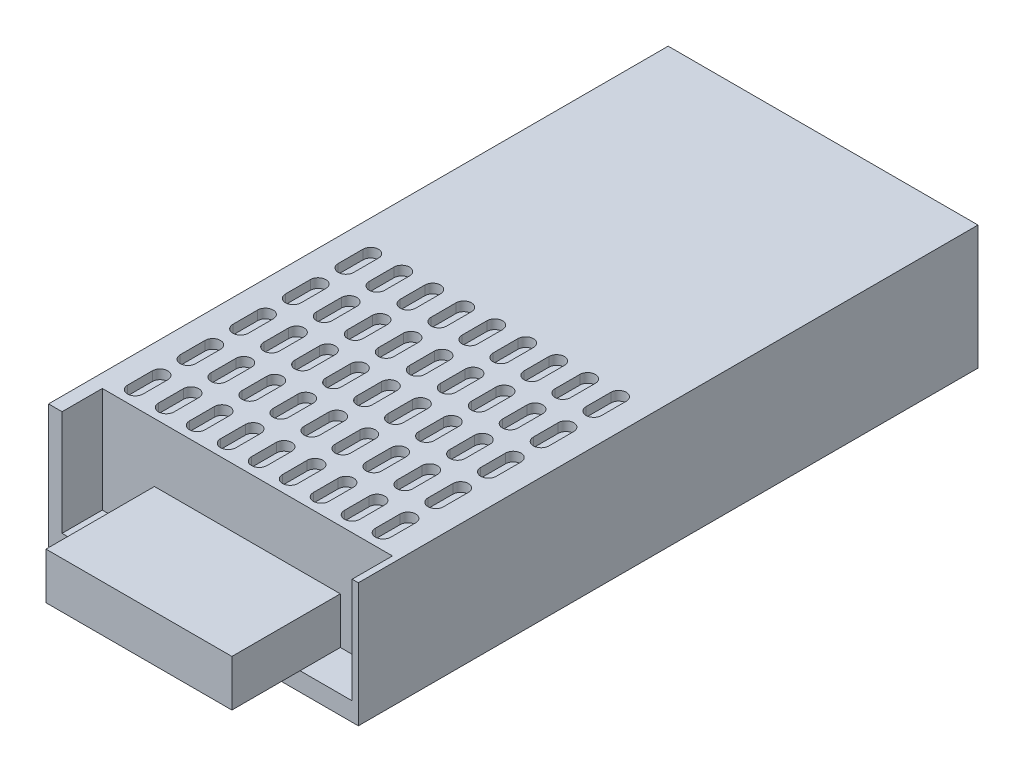
from build123d import *

# Parameters (mm, degrees)
SKETCH1_W           = 100
SKETCH1_H           = 40
BOSS_EXTRUDE1_DEPTH = 200
SKETCH2_W           = 93.635790415
SKETCH2_H           = 13
CUT_EXTRUDE1_DEPTH  = 34
SKETCH3_W           = 60
SKETCH3_H           = 15
BOSS_EXTRUDE2_DEPTH = 35
CUT_EXTRUDE2_DEPTH  = 3


with BuildPart() as part:
    # Sketch1 → Boss-Extrude1 (new body)
    with BuildSketch(Plane.XY):
        with Locations((50, 20)):
            Rectangle(SKETCH1_W, SKETCH1_H)
    extrude(amount=BOSS_EXTRUDE1_DEPTH)

    # Sketch2 → Cut-Extrude1 (cut)
    with BuildSketch(Plane(origin=(0, 40, 0), x_dir=(1, 0, 0), z_dir=(0, 1, 0))):
        with Locations((51.182104792, -193.5)):
            Rectangle(SKETCH2_W, SKETCH2_H)
    extrude(amount=-CUT_EXTRUDE1_DEPTH, mode=Mode.SUBTRACT)

    # Sketch3 → Boss-Extrude2 (add)
    with BuildSketch(Plane.XY.offset(187)):
        with Locations((51.182104792, 13.5)):
            Rectangle(SKETCH3_W, SKETCH3_H)
    extrude(amount=BOSS_EXTRUDE2_DEPTH)

    # Sketch4 → Cut-Extrude2 (cut)
    with BuildSketch(Plane(origin=(0, 40, 0), x_dir=(1, 0, 0), z_dir=(0, 1, 0))):
        with BuildLine():
            Line((7.5, -174), (7.5, -182))
            ThreePointArc((7.5, -182), (10, -184.5), (12.5, -182))
            Line((12.5, -182), (12.5, -174))
            ThreePointArc((12.5, -174), (10, -171.5), (7.5, -174))
        make_face()
        with BuildLine():
            Line((17.5, -174), (17.5, -182))
            ThreePointArc((17.5, -182), (20, -184.5), (22.5, -182))
            Line((22.5, -182), (22.5, -174))
            ThreePointArc((22.5, -174), (20, -171.5), (17.5, -174))
        make_face()
        with BuildLine():
            Line((27.5, -174), (27.5, -182))
            ThreePointArc((27.5, -182), (30, -184.5), (32.5, -182))
            Line((32.5, -182), (32.5, -174))
            ThreePointArc((32.5, -174), (30, -171.5), (27.5, -174))
        make_face()
        with BuildLine():
            Line((37.5, -174), (37.5, -182))
            ThreePointArc((37.5, -182), (40, -184.5), (42.5, -182))
            Line((42.5, -182), (42.5, -174))
            ThreePointArc((42.5, -174), (40, -171.5), (37.5, -174))
        make_face()
        with BuildLine():
            Line((47.5, -174), (47.5, -182))
            ThreePointArc((47.5, -182), (50, -184.5), (52.5, -182))
            Line((52.5, -182), (52.5, -174))
            ThreePointArc((52.5, -174), (50, -171.5), (47.5, -174))
        make_face()
        with BuildLine():
            Line((57.5, -174), (57.5, -182))
            ThreePointArc((57.5, -182), (60, -184.5), (62.5, -182))
            Line((62.5, -182), (62.5, -174))
            ThreePointArc((62.5, -174), (60, -171.5), (57.5, -174))
        make_face()
        with BuildLine():
            Line((67.5, -174), (67.5, -182))
            ThreePointArc((67.5, -182), (70, -184.5), (72.5, -182))
            Line((72.5, -182), (72.5, -174))
            ThreePointArc((72.5, -174), (70, -171.5), (67.5, -174))
        make_face()
        with BuildLine():
            Line((77.5, -174), (77.5, -182))
            ThreePointArc((77.5, -182), (80, -184.5), (82.5, -182))
            Line((82.5, -182), (82.5, -174))
            ThreePointArc((82.5, -174), (80, -171.5), (77.5, -174))
        make_face()
        with BuildLine():
            Line((87.5, -174), (87.5, -182))
            ThreePointArc((87.5, -182), (90, -184.5), (92.5, -182))
            Line((92.5, -182), (92.5, -174))
            ThreePointArc((92.5, -174), (90, -171.5), (87.5, -174))
        make_face()
        with BuildLine():
            Line((17.5, -157), (17.5, -165))
            ThreePointArc((17.5, -165), (20, -167.5), (22.5, -165))
            Line((22.5, -165), (22.5, -157))
            ThreePointArc((22.5, -157), (20, -154.5), (17.5, -157))
        make_face()
        with BuildLine():
            Line((27.5, -157), (27.5, -165))
            ThreePointArc((27.5, -165), (30, -167.5), (32.5, -165))
            Line((32.5, -165), (32.5, -157))
            ThreePointArc((32.5, -157), (30, -154.5), (27.5, -157))
        make_face()
        with BuildLine():
            Line((37.5, -157), (37.5, -165))
            ThreePointArc((37.5, -165), (40, -167.5), (42.5, -165))
            Line((42.5, -165), (42.5, -157))
            ThreePointArc((42.5, -157), (40, -154.5), (37.5, -157))
        make_face()
        with BuildLine():
            Line((47.5, -157), (47.5, -165))
            ThreePointArc((47.5, -165), (50, -167.5), (52.5, -165))
            Line((52.5, -165), (52.5, -157))
            ThreePointArc((52.5, -157), (50, -154.5), (47.5, -157))
        make_face()
        with BuildLine():
            Line((57.5, -157), (57.5, -165))
            ThreePointArc((57.5, -165), (60, -167.5), (62.5, -165))
            Line((62.5, -165), (62.5, -157))
            ThreePointArc((62.5, -157), (60, -154.5), (57.5, -157))
        make_face()
        with BuildLine():
            Line((67.5, -157), (67.5, -165))
            ThreePointArc((67.5, -165), (70, -167.5), (72.5, -165))
            Line((72.5, -165), (72.5, -157))
            ThreePointArc((72.5, -157), (70, -154.5), (67.5, -157))
        make_face()
        with BuildLine():
            Line((77.5, -157), (77.5, -165))
            ThreePointArc((77.5, -165), (80, -167.5), (82.5, -165))
            Line((82.5, -165), (82.5, -157))
            ThreePointArc((82.5, -157), (80, -154.5), (77.5, -157))
        make_face()
        with BuildLine():
            Line((87.5, -157), (87.5, -165))
            ThreePointArc((87.5, -165), (90, -167.5), (92.5, -165))
            Line((92.5, -165), (92.5, -157))
            ThreePointArc((92.5, -157), (90, -154.5), (87.5, -157))
        make_face()
        with BuildLine():
            Line((17.5, -140), (17.5, -148))
            ThreePointArc((17.5, -148), (20, -150.5), (22.5, -148))
            Line((22.5, -148), (22.5, -140))
            ThreePointArc((22.5, -140), (20, -137.5), (17.5, -140))
        make_face()
        with BuildLine():
            Line((27.5, -140), (27.5, -148))
            ThreePointArc((27.5, -148), (30, -150.5), (32.5, -148))
            Line((32.5, -148), (32.5, -140))
            ThreePointArc((32.5, -140), (30, -137.5), (27.5, -140))
        make_face()
        with BuildLine():
            Line((37.5, -140), (37.5, -148))
            ThreePointArc((37.5, -148), (40, -150.5), (42.5, -148))
            Line((42.5, -148), (42.5, -140))
            ThreePointArc((42.5, -140), (40, -137.5), (37.5, -140))
        make_face()
        with BuildLine():
            Line((47.5, -140), (47.5, -148))
            ThreePointArc((47.5, -148), (50, -150.5), (52.5, -148))
            Line((52.5, -148), (52.5, -140))
            ThreePointArc((52.5, -140), (50, -137.5), (47.5, -140))
        make_face()
        with BuildLine():
            Line((57.5, -140), (57.5, -148))
            ThreePointArc((57.5, -148), (60, -150.5), (62.5, -148))
            Line((62.5, -148), (62.5, -140))
            ThreePointArc((62.5, -140), (60, -137.5), (57.5, -140))
        make_face()
        with BuildLine():
            Line((67.5, -140), (67.5, -148))
            ThreePointArc((67.5, -148), (70, -150.5), (72.5, -148))
            Line((72.5, -148), (72.5, -140))
            ThreePointArc((72.5, -140), (70, -137.5), (67.5, -140))
        make_face()
        with BuildLine():
            Line((77.5, -140), (77.5, -148))
            ThreePointArc((77.5, -148), (80, -150.5), (82.5, -148))
            Line((82.5, -148), (82.5, -140))
            ThreePointArc((82.5, -140), (80, -137.5), (77.5, -140))
        make_face()
        with BuildLine():
            Line((87.5, -140), (87.5, -148))
            ThreePointArc((87.5, -148), (90, -150.5), (92.5, -148))
            Line((92.5, -148), (92.5, -140))
            ThreePointArc((92.5, -140), (90, -137.5), (87.5, -140))
        make_face()
        with BuildLine():
            Line((17.5, -123), (17.5, -131))
            ThreePointArc((17.5, -131), (20, -133.5), (22.5, -131))
            Line((22.5, -131), (22.5, -123))
            ThreePointArc((22.5, -123), (20, -120.5), (17.5, -123))
        make_face()
        with BuildLine():
            Line((27.5, -123), (27.5, -131))
            ThreePointArc((27.5, -131), (30, -133.5), (32.5, -131))
            Line((32.5, -131), (32.5, -123))
            ThreePointArc((32.5, -123), (30, -120.5), (27.5, -123))
        make_face()
        with BuildLine():
            Line((37.5, -123), (37.5, -131))
            ThreePointArc((37.5, -131), (40, -133.5), (42.5, -131))
            Line((42.5, -131), (42.5, -123))
            ThreePointArc((42.5, -123), (40, -120.5), (37.5, -123))
        make_face()
        with BuildLine():
            Line((47.5, -123), (47.5, -131))
            ThreePointArc((47.5, -131), (50, -133.5), (52.5, -131))
            Line((52.5, -131), (52.5, -123))
            ThreePointArc((52.5, -123), (50, -120.5), (47.5, -123))
        make_face()
        with BuildLine():
            Line((57.5, -123), (57.5, -131))
            ThreePointArc((57.5, -131), (60, -133.5), (62.5, -131))
            Line((62.5, -131), (62.5, -123))
            ThreePointArc((62.5, -123), (60, -120.5), (57.5, -123))
        make_face()
        with BuildLine():
            Line((67.5, -123), (67.5, -131))
            ThreePointArc((67.5, -131), (70, -133.5), (72.5, -131))
            Line((72.5, -131), (72.5, -123))
            ThreePointArc((72.5, -123), (70, -120.5), (67.5, -123))
        make_face()
        with BuildLine():
            Line((77.5, -123), (77.5, -131))
            ThreePointArc((77.5, -131), (80, -133.5), (82.5, -131))
            Line((82.5, -131), (82.5, -123))
            ThreePointArc((82.5, -123), (80, -120.5), (77.5, -123))
        make_face()
        with BuildLine():
            Line((87.5, -123), (87.5, -131))
            ThreePointArc((87.5, -131), (90, -133.5), (92.5, -131))
            Line((92.5, -131), (92.5, -123))
            ThreePointArc((92.5, -123), (90, -120.5), (87.5, -123))
        make_face()
        with BuildLine():
            Line((17.5, -106), (17.5, -114))
            ThreePointArc((17.5, -114), (20, -116.5), (22.5, -114))
            Line((22.5, -114), (22.5, -106))
            ThreePointArc((22.5, -106), (20, -103.5), (17.5, -106))
        make_face()
        with BuildLine():
            Line((27.5, -106), (27.5, -114))
            ThreePointArc((27.5, -114), (30, -116.5), (32.5, -114))
            Line((32.5, -114), (32.5, -106))
            ThreePointArc((32.5, -106), (30, -103.5), (27.5, -106))
        make_face()
        with BuildLine():
            Line((37.5, -106), (37.5, -114))
            ThreePointArc((37.5, -114), (40, -116.5), (42.5, -114))
            Line((42.5, -114), (42.5, -106))
            ThreePointArc((42.5, -106), (40, -103.5), (37.5, -106))
        make_face()
        with BuildLine():
            Line((47.5, -106), (47.5, -114))
            ThreePointArc((47.5, -114), (50, -116.5), (52.5, -114))
            Line((52.5, -114), (52.5, -106))
            ThreePointArc((52.5, -106), (50, -103.5), (47.5, -106))
        make_face()
        with BuildLine():
            Line((57.5, -106), (57.5, -114))
            ThreePointArc((57.5, -114), (60, -116.5), (62.5, -114))
            Line((62.5, -114), (62.5, -106))
            ThreePointArc((62.5, -106), (60, -103.5), (57.5, -106))
        make_face()
        with BuildLine():
            Line((67.5, -106), (67.5, -114))
            ThreePointArc((67.5, -114), (70, -116.5), (72.5, -114))
            Line((72.5, -114), (72.5, -106))
            ThreePointArc((72.5, -106), (70, -103.5), (67.5, -106))
        make_face()
        with BuildLine():
            Line((77.5, -106), (77.5, -114))
            ThreePointArc((77.5, -114), (80, -116.5), (82.5, -114))
            Line((82.5, -114), (82.5, -106))
            ThreePointArc((82.5, -106), (80, -103.5), (77.5, -106))
        make_face()
        with BuildLine():
            Line((87.5, -106), (87.5, -114))
            ThreePointArc((87.5, -114), (90, -116.5), (92.5, -114))
            Line((92.5, -114), (92.5, -106))
            ThreePointArc((92.5, -106), (90, -103.5), (87.5, -106))
        make_face()
        with BuildLine():
            Line((7.5, -157), (7.5, -165))
            ThreePointArc((7.5, -165), (10, -167.5), (12.5, -165))
            Line((12.5, -165), (12.5, -157))
            ThreePointArc((12.5, -157), (10, -154.5), (7.5, -157))
        make_face()
        with BuildLine():
            Line((7.5, -140), (7.5, -148))
            ThreePointArc((7.5, -148), (10, -150.5), (12.5, -148))
            Line((12.5, -148), (12.5, -140))
            ThreePointArc((12.5, -140), (10, -137.5), (7.5, -140))
        make_face()
        with BuildLine():
            Line((7.5, -123), (7.5, -131))
            ThreePointArc((7.5, -131), (10, -133.5), (12.5, -131))
            Line((12.5, -131), (12.5, -123))
            ThreePointArc((12.5, -123), (10, -120.5), (7.5, -123))
        make_face()
        with BuildLine():
            Line((7.5, -106), (7.5, -114))
            ThreePointArc((7.5, -114), (10, -116.5), (12.5, -114))
            Line((12.5, -114), (12.5, -106))
            ThreePointArc((12.5, -106), (10, -103.5), (7.5, -106))
        make_face()
    extrude(amount=-CUT_EXTRUDE2_DEPTH, mode=Mode.SUBTRACT)


solid = part.part
